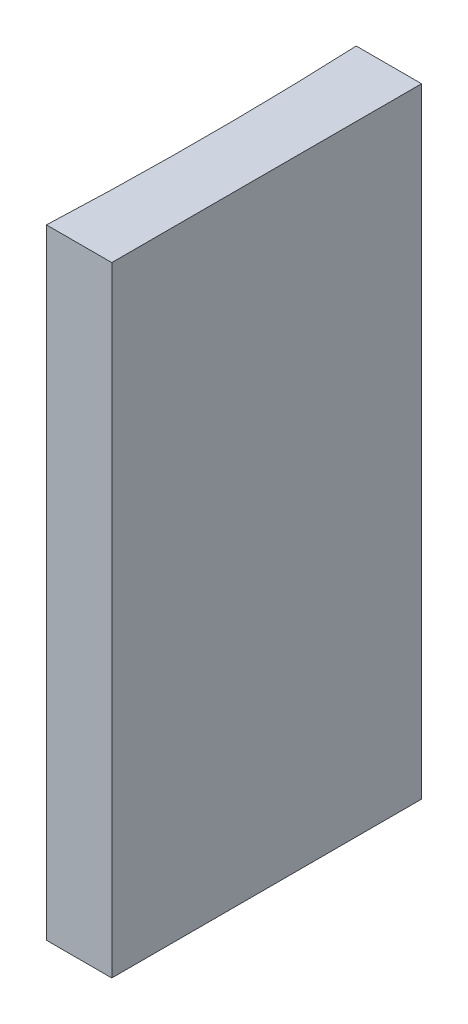
from build123d import *

# Parameters (mm, degrees)
EXTRUDE_1_DEPTH = 20


with BuildPart() as part:
    # 草图1 → 凸台-拉伸1 (new body)
    with BuildSketch(Plane(origin=(0, 0, 0), x_dir=(1, 0, 0), z_dir=(0, 1, 0))):
        with BuildLine():
            Line((0, 0), (0, -10))
            Line((0, -10), (-2.109107942, -10))
            ThreePointArc((-2.109107942, -10), (-2, -5), (-2.109107942, 0))
            Line((-2.109107942, 0), (0, 0))
        make_face()
    extrude(amount=EXTRUDE_1_DEPTH)


solid = part.part
